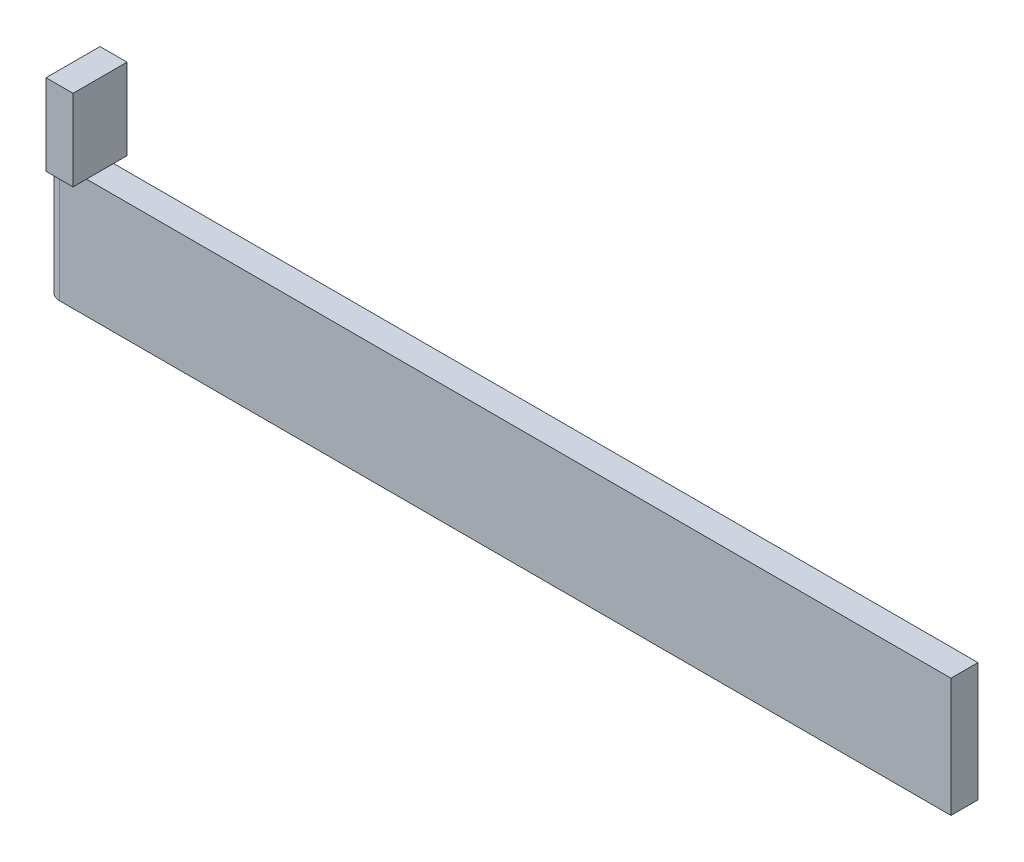
from build123d import *

# Parameters (mm, degrees)
SKETCH1_W           = 165
SKETCH1_H           = 22
BOSS_EXTRUDE1_DEPTH = 5
SKETCH2_W           = 10
SKETCH2_H           = 15
BOSS_EXTRUDE2_DEPTH = 5
SKETCH3_R           = 2.5
BOSS_EXTRUDE3_DEPTH = 22


with BuildPart() as part:
    # Sketch1 → Boss-Extrude1 (new body)
    with BuildSketch(Plane.XY):
        with Locations((82.5, 11)):
            Rectangle(SKETCH1_W, SKETCH1_H)
    extrude(amount=BOSS_EXTRUDE1_DEPTH)

    # Sketch2 → Boss-Extrude2 (add)
    with BuildSketch(Plane.ZY):
        with Locations((2.5, 29.5)):
            Rectangle(SKETCH2_W, SKETCH2_H)
    extrude(amount=-BOSS_EXTRUDE2_DEPTH)

    # Sketch3 → Boss-Extrude3 (add)
    with BuildSketch(Plane(origin=(0, 22, 0), x_dir=(1, 0, 0), z_dir=(0, 1, 0))):
        with Locations((0, -2.5)):
            Circle(SKETCH3_R)
    extrude(amount=-BOSS_EXTRUDE3_DEPTH)


solid = part.part
